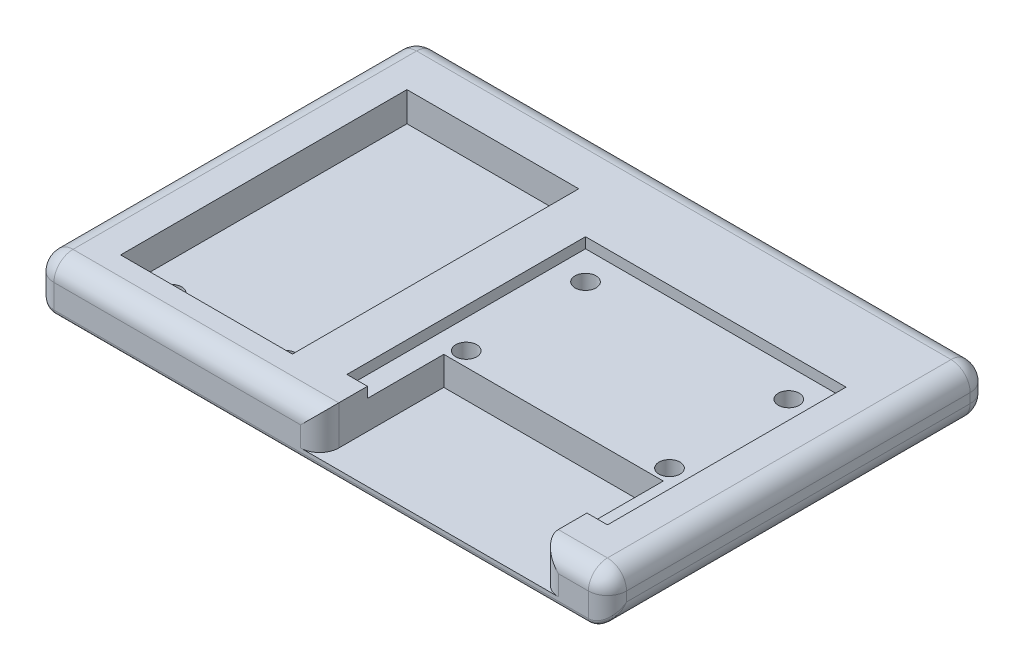
from build123d import *

# Parameters (mm, degrees)
SKETCH1_W               = 60
SKETCH1_H               = 40
BOSS_EXTRUDE1_DEPTH     = 5
SKETCH2_W               = 18
SKETCH2_H               = 30
SKETCH2_R               = 1.1
SKETCH2_W_2             = 27.3
SKETCH2_H_2             = 25
CUT_EXTRUDE1_DEPTH      = 1.1
SKETCH3_W               = 18
SKETCH3_H               = 30
SKETCH3_R               = 1.1
CUT_EXTRUDE2_DEPTH      = 2
SKETCH4_W               = 23
SKETCH4_H               = 13
CUT_EXTRUDE3_DEPTH      = 4
CUT_EXTRUDE3_DEPTH_BACK = 3
SKETCH5_R               = 1.1
CUT_EXTRUDE4_DEPTH      = 6
FILLET1_R               = 2
FILLET2_R               = 0.5


with BuildPart() as part:
    # Sketch1 → Boss-Extrude1 (new body)
    with BuildSketch(Plane(origin=(0, 0, 0), x_dir=(1, 0, 0), z_dir=(0, 1, 0))):
        Rectangle(SKETCH1_W, SKETCH1_H)
    extrude(amount=BOSS_EXTRUDE1_DEPTH)

    # Sketch2 → Cut-Extrude1 (cut)
    with BuildSketch(Plane(origin=(0, 5, 0), x_dir=(1, 0, 0), z_dir=(0, 1, 0))):
        with Locations((-16, -1.01)):
            Rectangle(SKETCH2_W, SKETCH2_H)
        with Locations((-22, -13.71)):
            Circle(SKETCH2_R, mode=Mode.SUBTRACT)
        with Locations((-10, -13.71)):
            Circle(SKETCH2_R, mode=Mode.SUBTRACT)
        with Locations((11.35, -2.5)):
            Rectangle(SKETCH2_W_2, SKETCH2_H_2)
        with Locations((0.7, 7)):
            Circle(SKETCH2_R, mode=Mode.SUBTRACT)
        with Locations((0.7, -5.5)):
            Circle(SKETCH2_R, mode=Mode.SUBTRACT)
        with Locations((22, -5.5)):
            Circle(SKETCH2_R, mode=Mode.SUBTRACT)
        with Locations((22, 7)):
            Circle(SKETCH2_R, mode=Mode.SUBTRACT)
    extrude(amount=-CUT_EXTRUDE1_DEPTH, mode=Mode.SUBTRACT)

    # Sketch3 → Cut-Extrude2 (cut)
    with BuildSketch(Plane(origin=(0, 3.9, 0), x_dir=(1, 0, 0), z_dir=(0, 1, 0))):
        with Locations((-16, -1.01)):
            Rectangle(SKETCH3_W, SKETCH3_H)
        with Locations((-10, -13.71)):
            Circle(SKETCH3_R, mode=Mode.SUBTRACT)
        with Locations((-22, -13.71)):
            Circle(SKETCH3_R, mode=Mode.SUBTRACT)
    extrude(amount=-CUT_EXTRUDE2_DEPTH, mode=Mode.SUBTRACT)

    # Sketch4 → Cut-Extrude3 (cut, two sides)
    with BuildSketch(Plane(origin=(0, 3.9, 0), x_dir=(1, 0, 0), z_dir=(0, 1, 0))) as cut_extrude3_sk:
        with Locations((11.35, -13.5)):
            Rectangle(SKETCH4_W, SKETCH4_H)
    extrude(amount=CUT_EXTRUDE3_DEPTH, mode=Mode.SUBTRACT)
    extrude(cut_extrude3_sk.sketch, amount=-CUT_EXTRUDE3_DEPTH_BACK, mode=Mode.SUBTRACT)

    # Sketch5 → Cut-Extrude4 (cut, through all)
    with BuildSketch(Plane(origin=(0, 5, 0), x_dir=(1, 0, 0), z_dir=(0, 1, 0))):
        with Locations((22, 7)):
            Circle(SKETCH5_R)
        with Locations((22, -5.5)):
            Circle(SKETCH5_R)
        with Locations((0.7, -5.5)):
            Circle(SKETCH5_R)
        with Locations((0.7, 7)):
            Circle(SKETCH5_R)
        with Locations((-10, -13.71)):
            Circle(SKETCH5_R)
        with Locations((-22, -13.71)):
            Circle(SKETCH5_R)
    extrude(amount=-CUT_EXTRUDE4_DEPTH, mode=Mode.SUBTRACT)

    # Fillet1
    fillet1_edges = [part.edges().sort_by_distance(p)[0] for p in [
        (-30, 5, 0),
        (-15.075, 5, 20),
        (30, 5, 0),
        (-30, 0, 0),
        (0, 0, -20),
        (30, 0, 0),
        (30, 2.5, 20),
        (-30, 2.5, 20),
        (-30, 2.5, -20),
        (30, 2.5, -20),
        (26.425, 5, 20),
        (-0.15, 2.95, 20),
        (22.85, 2.95, 20),
        (0, 5, -20),
    ]]
    fillet(fillet1_edges, radius=FILLET1_R)

    # Fillet2
    fillet2_edges = [part.edges().sort_by_distance(p)[0] for p in [
        (0, 0, 20),
        (29.526592034, 0.707902185, 19.292097815),
        (-29.526592034, 0.707902185, 19.292097815),
    ]]
    fillet(fillet2_edges, radius=FILLET2_R)


solid = part.part
